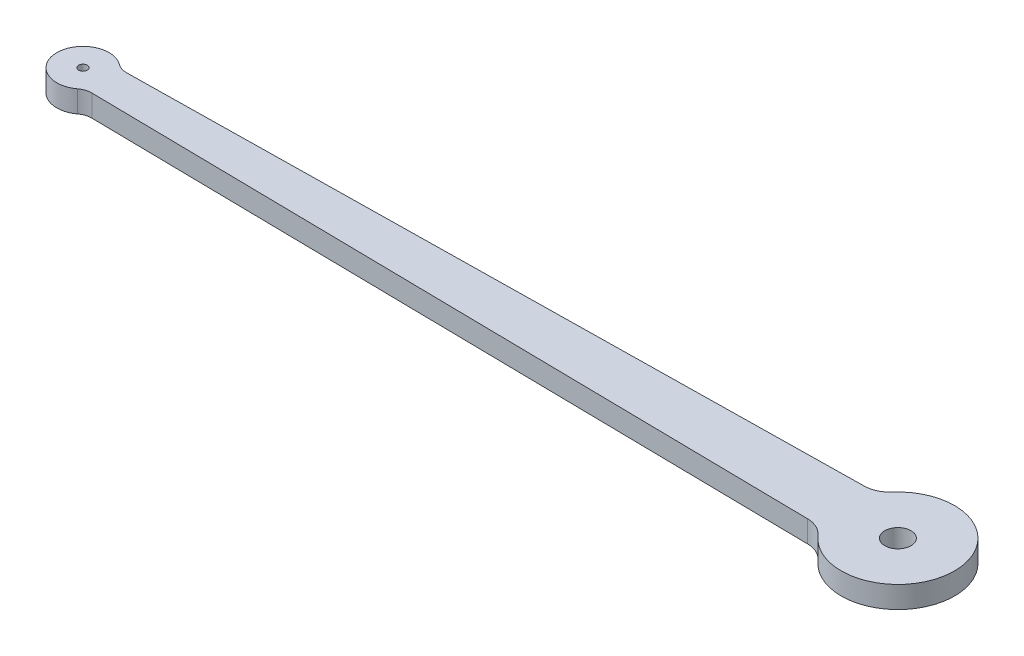
from build123d import *

# Parameters (mm, degrees)
BOSS_EXTRUDE1_DEPTH = 2.5
CUT_EXTRUDE1_REACH  = 4.5
SKETCH2_R           = 0.5
SKETCH2_R_2         = 1.5


with BuildPart() as part:
    # Sketch1 → Boss-Extrude1 (new body)
    with BuildSketch(Plane(origin=(0, 0, 0), x_dir=(1, 0, 0), z_dir=(0, 1, 0))):
        with BuildLine():
            Line((39.640142036, 3.25), (-43.719713181, 2))
            ThreePointArc((-43.719713181, 2), (-44.367984766, 2.097743563), (-44.949820159, 2.399865109))
            ThreePointArc((-44.949820159, 2.399865109), (-49.75, 0), (-44.949820159, -2.399865109))
            ThreePointArc((-44.949820159, -2.399865109), (-44.367984766, -2.097743563), (-43.719713181, -2))
            Line((-43.719713181, -2), (39.640142036, -3.25))
            ThreePointArc((39.640142036, -3.25), (40.856423208, -3.52767477), (41.854584123, -4.276085054))
            ThreePointArc((41.854584123, -4.276085054), (53.25, 0), (41.854584123, 4.276085054))
            ThreePointArc((41.854584123, 4.276085054), (40.856423208, 3.52767477), (39.640142036, 3.25))
        make_face()
    extrude(amount=BOSS_EXTRUDE1_DEPTH)

    # Sketch2 → Cut-Extrude1 (cut, up to next)
    with BuildSketch(Plane(origin=(0, 2.5, 0), x_dir=(1, 0, 0), z_dir=(0, 1, 0)), mode=Mode.PRIVATE) as cut_extrude1_sk1:
        with Locations((-46.75, 0)):
            Circle(SKETCH2_R)
    cut_extrude1_tool1 = extrude(cut_extrude1_sk1.sketch, amount=-CUT_EXTRUDE1_REACH, mode=Mode.PRIVATE) & part.part
    add(cut_extrude1_tool1.solids().sort_by_distance((-46.75, 2.5, 0))[0], mode=Mode.SUBTRACT)
    # Sketch2 → Cut-Extrude1 (cut, up to next)
    with BuildSketch(Plane(origin=(0, 2.5, 0), x_dir=(1, 0, 0), z_dir=(0, 1, 0)), mode=Mode.PRIVATE) as cut_extrude1_sk2:
        with Locations((46.75, 0)):
            Circle(SKETCH2_R_2)
    cut_extrude1_tool2 = extrude(cut_extrude1_sk2.sketch, amount=-CUT_EXTRUDE1_REACH, mode=Mode.PRIVATE) & part.part
    add(cut_extrude1_tool2.solids().sort_by_distance((46.75, 2.5, 0))[0], mode=Mode.SUBTRACT)


solid = part.part
